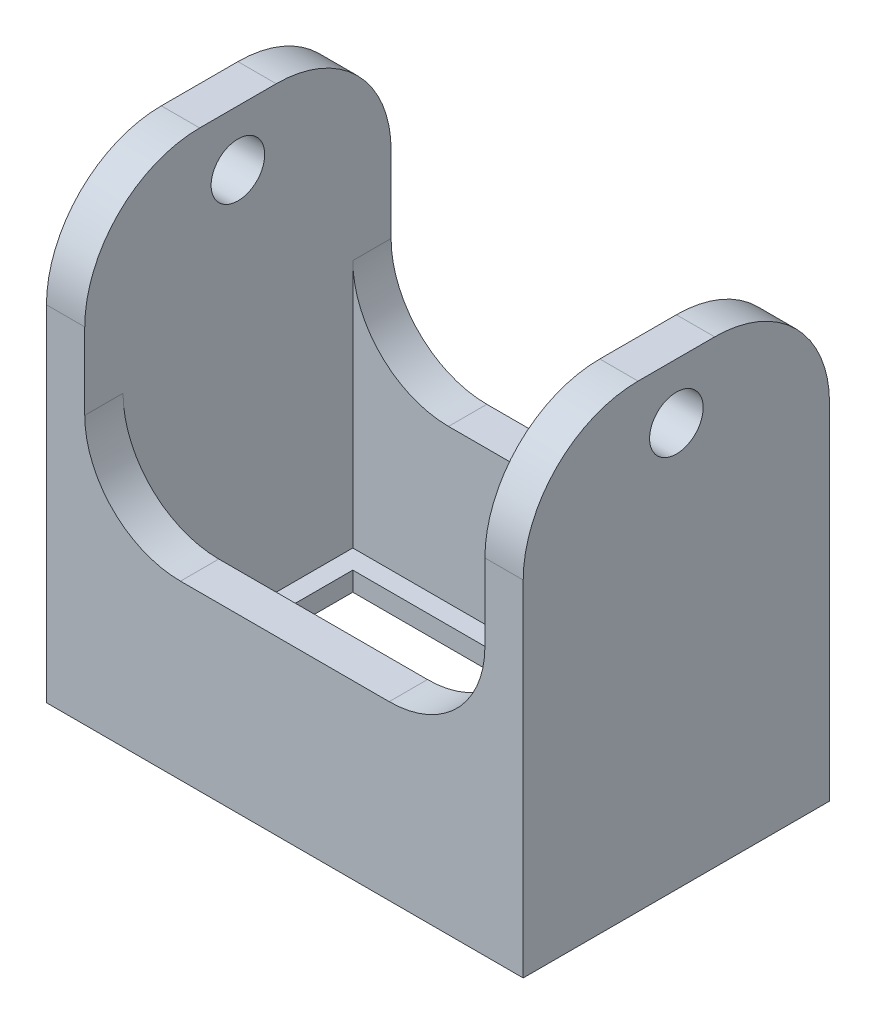
from build123d import *

# Parameters (mm, degrees)
SKETCH1_W           = 24.9
SKETCH1_H           = 16
SKETCH1_W_2         = 18.9
SKETCH1_H_2         = 10
BOSS_EXTRUDE1_DEPTH = 1
SKETCH2_W           = 24.9
SKETCH2_H           = 16
SKETCH2_W_2         = 20.9
SKETCH2_H_2         = 12
BOSS_EXTRUDE2_DEPTH = 8
SKETCH3_W           = 2
SKETCH3_H           = 16
BOSS_EXTRUDE3_DEPTH = 15
FILLET1_R           = 5
SKETCH4_R           = 1.4
CUT_EXTRUDE1_DEPTH  = 24.9
FILLET2_R           = 6


with BuildPart() as part:
    # Sketch1 → Boss-Extrude1 (new body)
    with BuildSketch(Plane(origin=(0, 0, 0), x_dir=(1, 0, 0), z_dir=(0, 1, 0))):
        Rectangle(SKETCH1_W, SKETCH1_H)
        Rectangle(SKETCH1_W_2, SKETCH1_H_2, mode=Mode.SUBTRACT)
    extrude(amount=BOSS_EXTRUDE1_DEPTH)

    # Sketch2 → Boss-Extrude2 (add)
    with BuildSketch(Plane(origin=(0, 1, 0), x_dir=(1, 0, 0), z_dir=(0, 1, 0))):
        Rectangle(SKETCH2_W, SKETCH2_H)
        Rectangle(SKETCH2_W_2, SKETCH2_H_2, mode=Mode.SUBTRACT)
    extrude(amount=BOSS_EXTRUDE2_DEPTH)

    # Sketch3 → Boss-Extrude3 (add)
    with BuildSketch(Plane(origin=(0, 9, 0), x_dir=(1, 0, 0), z_dir=(0, 1, 0))):
        with Locations((-11.45, 0)):
            Rectangle(SKETCH3_W, SKETCH3_H)
        with Locations((11.45, 0)):
            Rectangle(SKETCH3_W, SKETCH3_H)
    extrude(amount=BOSS_EXTRUDE3_DEPTH)

    # Fillet1
    fillet1_edges = [part.edges().sort_by_distance(p)[0] for p in [
        (-10.45, 9, -7),
        (-10.45, 9, 7),
        (10.45, 9, 7),
        (10.45, 9, -7),
    ]]
    fillet(fillet1_edges, radius=FILLET1_R)

    # Sketch4 → Cut-Extrude1 (cut)
    with BuildSketch(Plane(origin=(12.45, 0, 0), x_dir=(0, 0, -1), z_dir=(1, 0, 0))):
        with Locations((0, 21.1)):
            Circle(SKETCH4_R)
    extrude(amount=-CUT_EXTRUDE1_DEPTH, mode=Mode.SUBTRACT)

    # Fillet2
    fillet2_edges = [part.edges().sort_by_distance(p)[0] for p in [
        (11.45, 24, -8),
        (11.45, 24, 8),
        (-11.45, 24, 8),
        (-11.45, 24, -8),
    ]]
    fillet(fillet2_edges, radius=FILLET2_R)


solid = part.part
